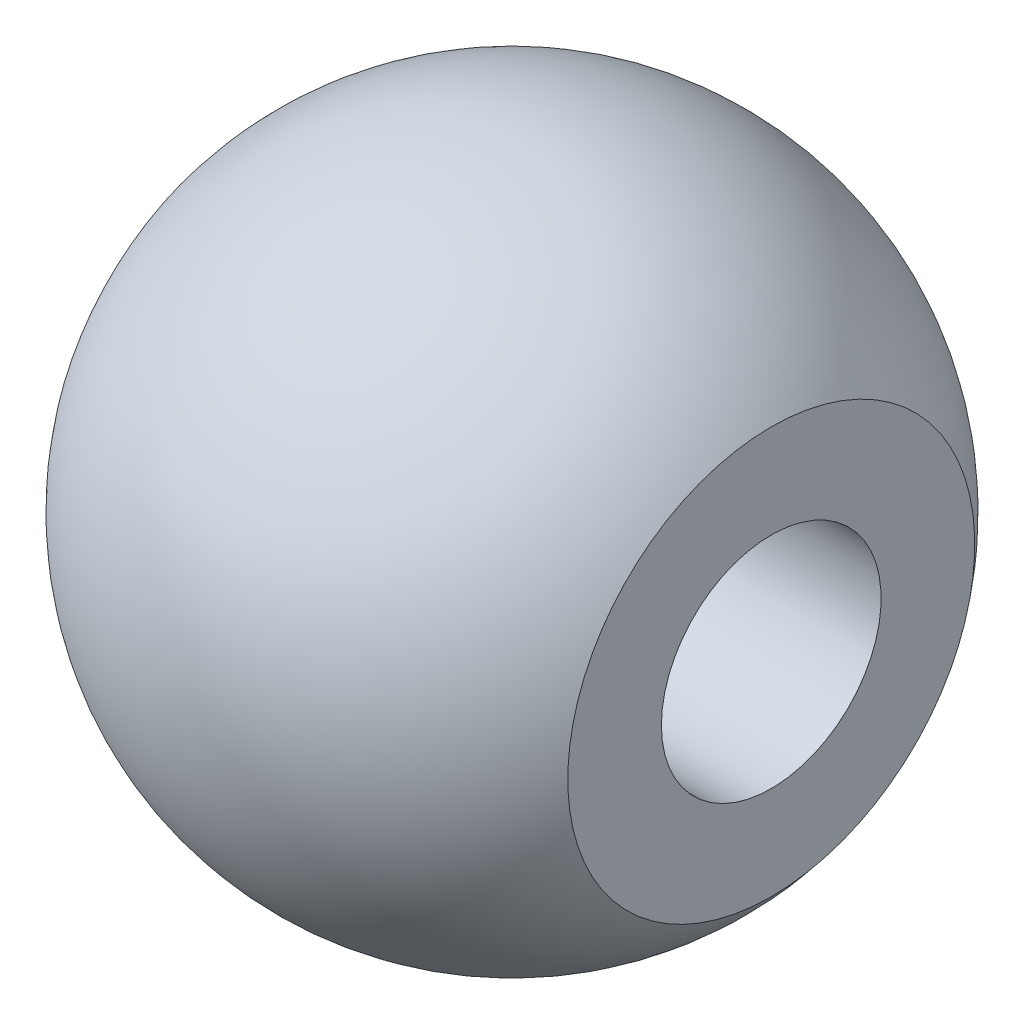
from build123d import *

# Parameters (mm, degrees)
CUT_EXTRUDE2_DEPTH      = 7
CUT_EXTRUDE2_DEPTH_BACK = 7


with BuildPart() as part:
    # Sketch1 → Revolve1 (revolve)
    with BuildSketch(Plane.XY):
        with BuildLine():
            Line((-6, 0), (6, 0))
            ThreePointArc((6, 0), (0, 6), (-6, 0))
        make_face()
    revolve(axis=Axis((-13.60120179, 0, 0), (1, 0, 0)))

    # Sketch2 → Cut-Extrude2 (cut, two sides)
    with BuildSketch(Plane.XY) as cut_extrude2_sk:
        with BuildLine():
            Line((-4.72, 3.704267809), (-4.72, -3.704267809))
            ThreePointArc((-4.72, -3.704267809), (-6, 0), (-4.72, 3.704267809))
        make_face()
        with BuildLine():
            Line((4.72, 3.704267809), (4.72, -3.704267809))
            ThreePointArc((4.72, -3.704267809), (6, 0), (4.72, 3.704267809))
        make_face()
    extrude(amount=CUT_EXTRUDE2_DEPTH, mode=Mode.SUBTRACT)
    extrude(cut_extrude2_sk.sketch, amount=-CUT_EXTRUDE2_DEPTH_BACK, mode=Mode.SUBTRACT)

    # Sketch3 → Cut-Revolve1 (revolve, cut)
    with BuildSketch(Plane.XY, mode=Mode.PRIVATE) as cut_revolve1_sk:
        Polygon((-4.72, 3.44), (-3.28, 2), (4.72, 2), (4.72, 0), (-4.72, 0), align=None)
    revolve(cut_revolve1_sk.sketch.rotate(Axis((-7.010525763, 0, 0), (1, 0, 0)), 90), axis=Axis((-7.010525763, 0, 0), (1, 0, 0)), mode=Mode.SUBTRACT)  # turned: the seam where the file's is


solid = part.part
